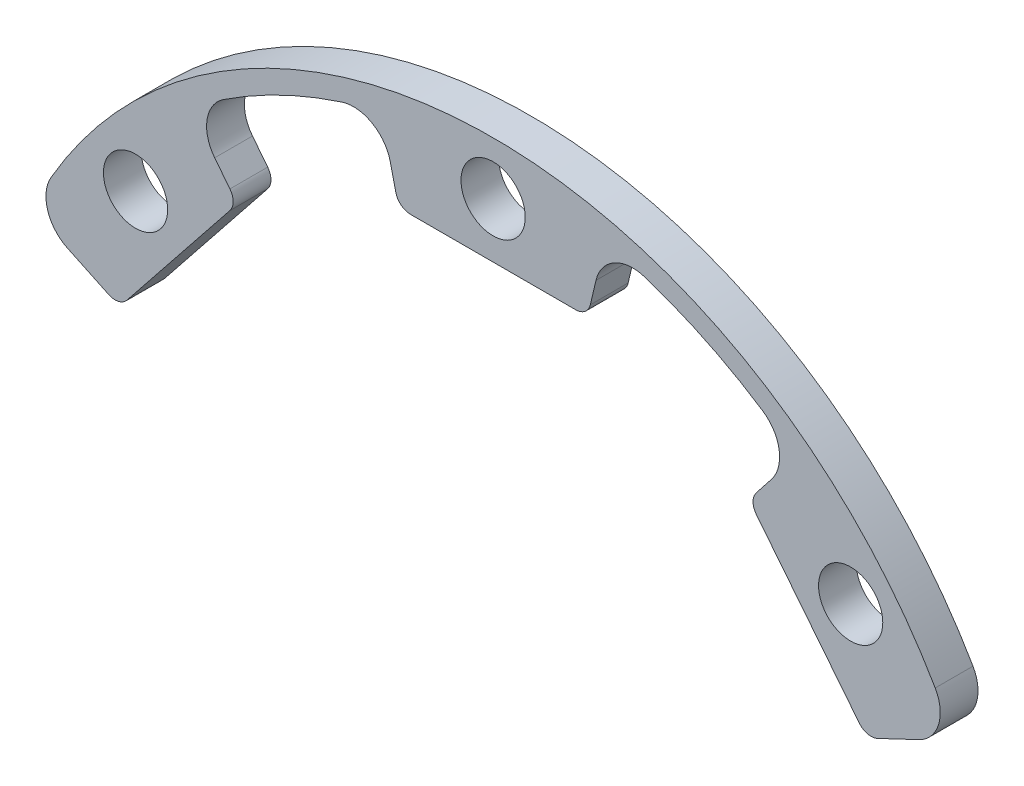
from build123d import *

# Parameters (mm, degrees)
ESQUISSE2_R        = 4.25
BOSS_EXTRU_1_DEPTH = 5
CONG_1_R           = 5
CONG_2_R           = 2


with BuildPart() as part:
    # Esquisse2 → Boss.-Extru.1 (new body)
    with BuildSketch(Plane.XY):
        with BuildLine():
            Line((-41.632526167, 33.200832294), (-33.836607647, 42.976604913))
            Line((-33.836607647, 42.976604913), (-40.054629461, 50.874248484))
            Line((-40.054629461, 50.874248484), (-41.75579133, 53.034930852))
            ThreePointArc((-41.75579133, 53.034930852), (-52.772575719, 42.086877432), (-60.995330499, 28.91054578))
            Line((-60.995330499, 28.91054578), (-49.426698361, 23.427249496))
            Line((-49.426698361, 23.427249496), (-41.632526167, 33.200832294))
        make_face()
        with Locations((-47.300804689, 37.721133012)):
            Circle(ESQUISSE2_R, mode=Mode.SUBTRACT)
        with BuildLine():
            Line((-41.75579133, 53.034930852), (-40.054629461, 50.874248484))
            ThreePointArc((-40.054629461, 50.874248484), (-28.093972108, 58.337734197), (-14.801436125, 63.035545438))
            Line((-14.801436125, 63.035545438), (-15.430068548, 65.712730765))
            ThreePointArc((-15.430068548, 65.712730765), (-29.28715239, 60.815398583), (-41.75579133, 53.034930852))
        make_face()
        with BuildLine():
            Line((-14.801436125, 63.035545438), (-12.503682933, 53.25))
            Line((-12.503682933, 53.25), (0, 53.25))
            Line((0, 53.25), (12.503682933, 53.25))
            Line((12.503682933, 53.25), (14.801436125, 63.035545438))
            Line((14.801436125, 63.035545438), (15.430068548, 65.712730765))
            ThreePointArc((15.430068548, 65.712730765), (0, 67.5), (-15.430068548, 65.712730765))
            Line((-15.430068548, 65.712730765), (-14.801436125, 63.035545438))
        make_face()
        with Locations((0, 60.5)):
            Circle(ESQUISSE2_R, mode=Mode.SUBTRACT)
        with BuildLine():
            Line((15.430068548, 65.712730765), (14.801436125, 63.035545438))
            ThreePointArc((14.801436125, 63.035545438), (28.093972108, 58.337734197), (40.054629461, 50.874248484))
            Line((40.054629461, 50.874248484), (41.75579133, 53.034930852))
            ThreePointArc((41.75579133, 53.034930852), (29.28715239, 60.815398583), (15.430068548, 65.712730765))
        make_face()
        with BuildLine():
            Line((41.75579133, 53.034930852), (40.054629461, 50.874248484))
            Line((40.054629461, 50.874248484), (33.836607647, 42.976604913))
            Line((33.836607647, 42.976604913), (41.632526363, 33.200832047))
            Line((41.632526363, 33.200832047), (49.426698361, 23.427249496))
            Line((49.426698361, 23.427249496), (60.995330499, 28.91054578))
            ThreePointArc((60.995330499, 28.91054578), (52.772575719, 42.086877432), (41.75579133, 53.034930852))
        make_face()
        with Locations((47.300804689, 37.721133012)):
            Circle(ESQUISSE2_R, mode=Mode.SUBTRACT)
    extrude(amount=BOSS_EXTRU_1_DEPTH)

    # Congé1
    cong_1_edges = [part.edges().sort_by_distance(p)[0] for p in [
        (60.995330499, 28.91054578, 2.5),
        (40.054629461, 50.874248484, 2.5),
        (14.801436125, 63.035545438, 2.5),
        (-14.801436125, 63.035545438, 2.5),
        (-40.054629461, 50.874248484, 2.5),
        (-60.995330499, 28.91054578, 2.5),
    ]]
    fillet(cong_1_edges, radius=CONG_1_R)

    # Congé2
    cong_2_edges = [part.edges().sort_by_distance(p)[0] for p in [
        (49.426698361, 23.427249496, 2.5),
        (33.836607647, 42.976604913, 2.5),
        (12.503682933, 53.25, 2.5),
        (-12.503682933, 53.25, 2.5),
        (-33.836607647, 42.976604913, 2.5),
        (-49.426698361, 23.427249496, 2.5),
    ]]
    fillet(cong_2_edges, radius=CONG_2_R)


solid = part.part
